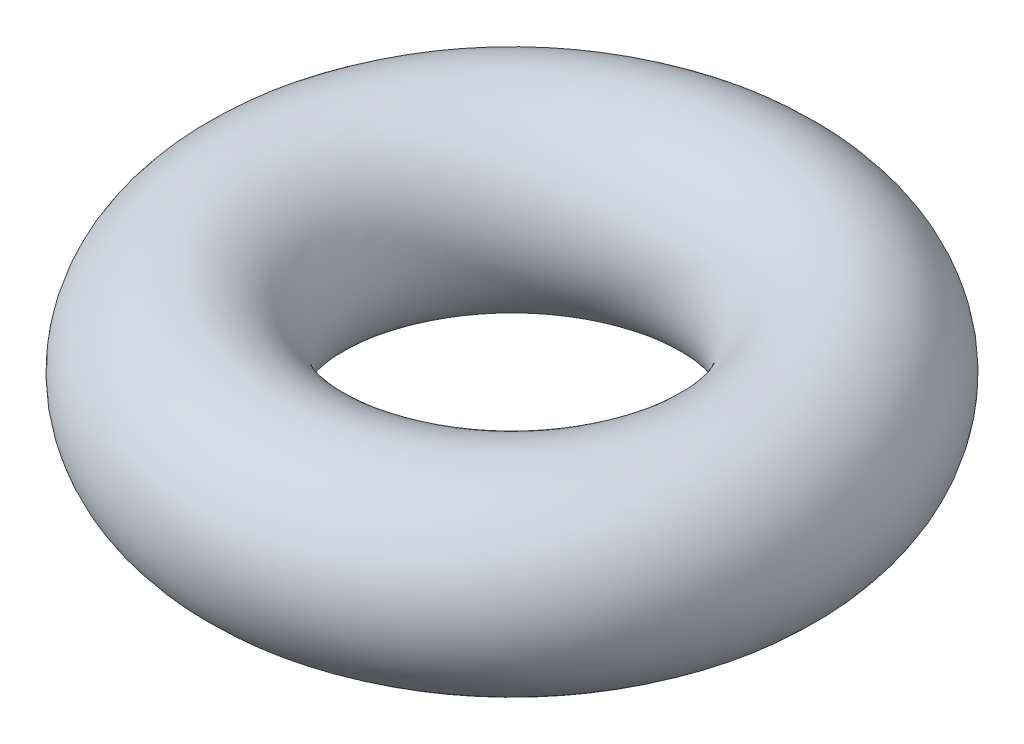
from build123d import *

# Parameters (mm, degrees)
CROQUIS1_R = 1


with BuildPart() as part:
    # Croquis1 → Revolución1 (revolve)
    with BuildSketch(Plane.XY):
        with Locations((2.5, 0)):
            Circle(CROQUIS1_R)
    revolve(axis=Axis((0, 0, 0), (0, 1, 0)))


solid = part.part
